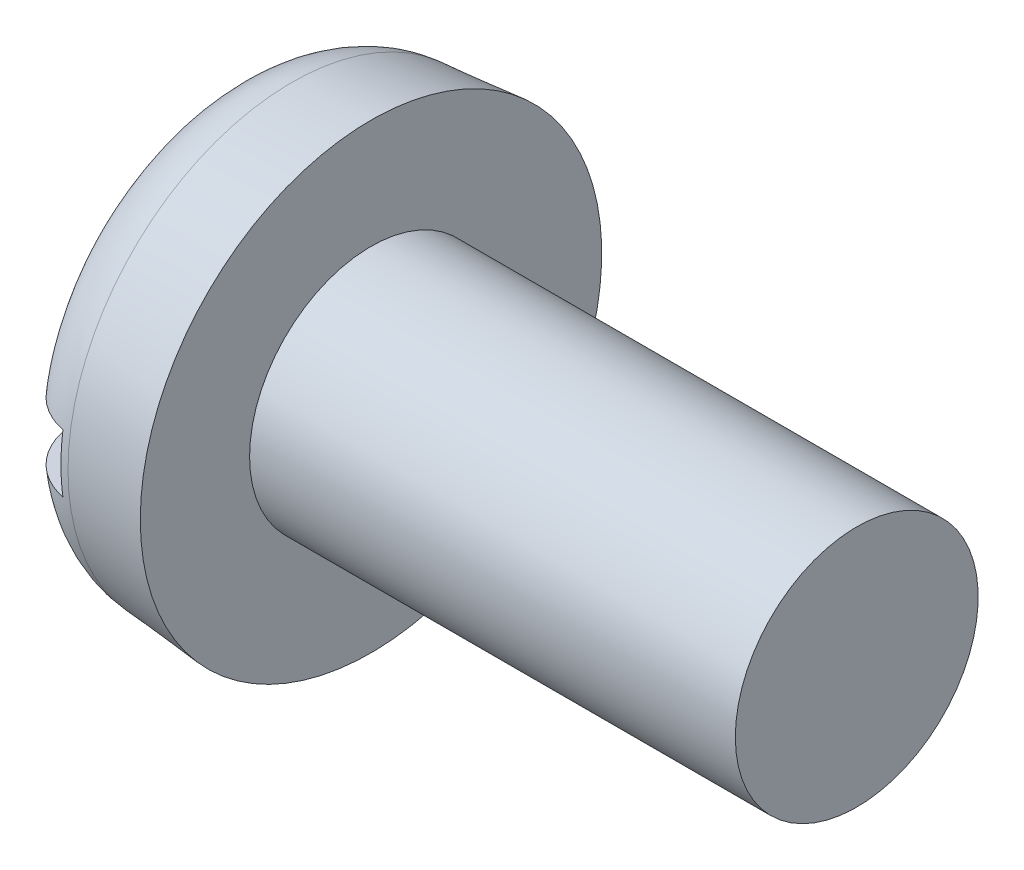
from build123d import *

# Parameters (mm, degrees)
FILLET2_R  = 1.5
SKETCH2_W  = 9.5
SKETCH2_H  = 1.2
SLOT_DEPTH = 1.2


with BuildPart() as part:
    # BodySke → Base-Revolve (revolve)
    with BuildSketch(Plane.XY, mode=Mode.PRIVATE) as base_revolve_sk:
        Polygon((3, 2.5), (3, 4.75), (0, 4.487534009), (0, 0), (13, 0), (13, 2.5), align=None)
    revolve(base_revolve_sk.sketch.rotate(Axis((-25.4, 0, 0), (1, 0, 0)), 90), axis=Axis((-25.4, 0, 0), (1, 0, 0)))  # turned: the seam where the file's is

    # Fillet2
    fillet2_edges = [part.edges().sort_by_distance(p)[0] for p in [
        (0, 0, -4.487534009),
    ]]
    fillet(fillet2_edges, radius=FILLET2_R)

    # Sketch2 → Slot (cut)
    with BuildSketch(Plane(origin=(0, 0, 0), x_dir=(0, 0, -1), z_dir=(1, 0, 0))):
        Rectangle(SKETCH2_W, SKETCH2_H)
    extrude(amount=SLOT_DEPTH, mode=Mode.SUBTRACT)


solid = part.part
